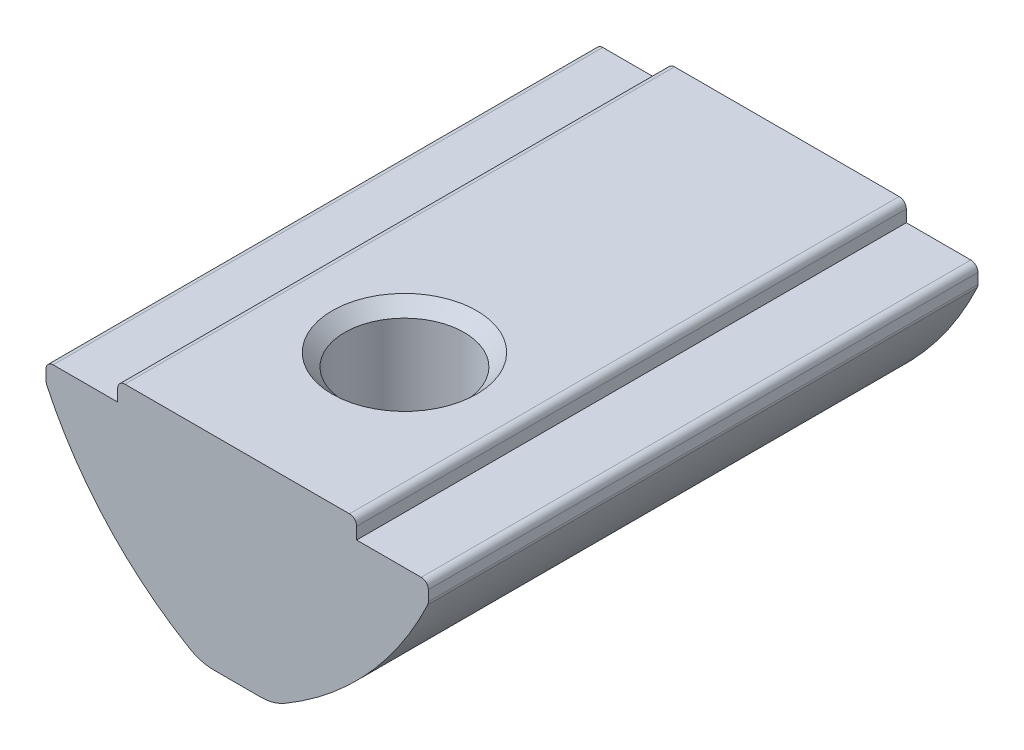
from build123d import *

# Parameters (mm, degrees)
EXTRUDE_1_DEPTH             = 11.5
FILLET_1_R                  = 0.3
FILLET_2_R                  = 2
HOLE_WIZARD_M63_D           = 5
HOLE_WIZARD_M63_CSINK_D     = 6.05
HOLE_WIZARD_M63_CSINK_ANGLE = 90


with BuildPart() as part:
    # Эскиз1 → Бобышка-Вытянуть1 (new body, symmetric)
    with BuildSketch(Plane.XY):
        with BuildLine():
            Line((-5, 0), (5, 0))
            Line((5, 0), (5, -0.8))
            Line((5, -0.8), (8, -0.8))
            Line((8, -0.8), (8, -1.6))
            ThreePointArc((8, -1.6), (5.309398779, -5.576969864), (1.5, -8.5))
            Line((1.5, -8.5), (-1.5, -8.5))
            ThreePointArc((-1.5, -8.5), (-5.309398779, -5.576969864), (-8, -1.6))
            Line((-8, -1.6), (-8, -0.8))
            Line((-8, -0.8), (-5, -0.8))
            Line((-5, -0.8), (-5, 0))
        make_face()
    extrude(amount=EXTRUDE_1_DEPTH, both=True)

    # Скругление1
    fillet_1_edges = [part.edges().sort_by_distance(p)[0] for p in [
        (8, -0.8, 0),
        (8, -1.6, 0),
        (-8, -1.6, 0),
        (-8, -0.8, 0),
        (-5, 0, 0),
        (5, 0, 0),
    ]]
    fillet(fillet_1_edges, radius=FILLET_1_R)

    # Скругление2
    fillet_2_edges = [part.edges().sort_by_distance(p)[0] for p in [
        (1.5, -8.5, 0),
        (-1.5, -8.5, 0),
    ]]
    fillet(fillet_2_edges, radius=FILLET_2_R)

    # Отверстие обработанное метчиком M63 (through all)
    with Locations(Plane(origin=(0, 0, 0), x_dir=(1, 0, 0), z_dir=(0, 1, 0))):
        with Locations((0, -4.5)):
            CounterSinkHole(HOLE_WIZARD_M63_D / 2, HOLE_WIZARD_M63_CSINK_D / 2, counter_sink_angle=HOLE_WIZARD_M63_CSINK_ANGLE)

    # Эскиз5 → Повернуть1 (revolve)
    with BuildSketch(Plane(origin=(0, 0, 0), x_dir=(0, 0, -1), z_dir=(1, 0, 0))):
        with BuildLine():
            Line((6.5, -4.3), (6.5, -9.3))
            ThreePointArc((6.5, -9.3), (4, -6.8), (6.5, -4.3))
        make_face()
    revolve(axis=Axis((0, -4.3, -6.5), (0, -1, 0)))


solid = part.part
